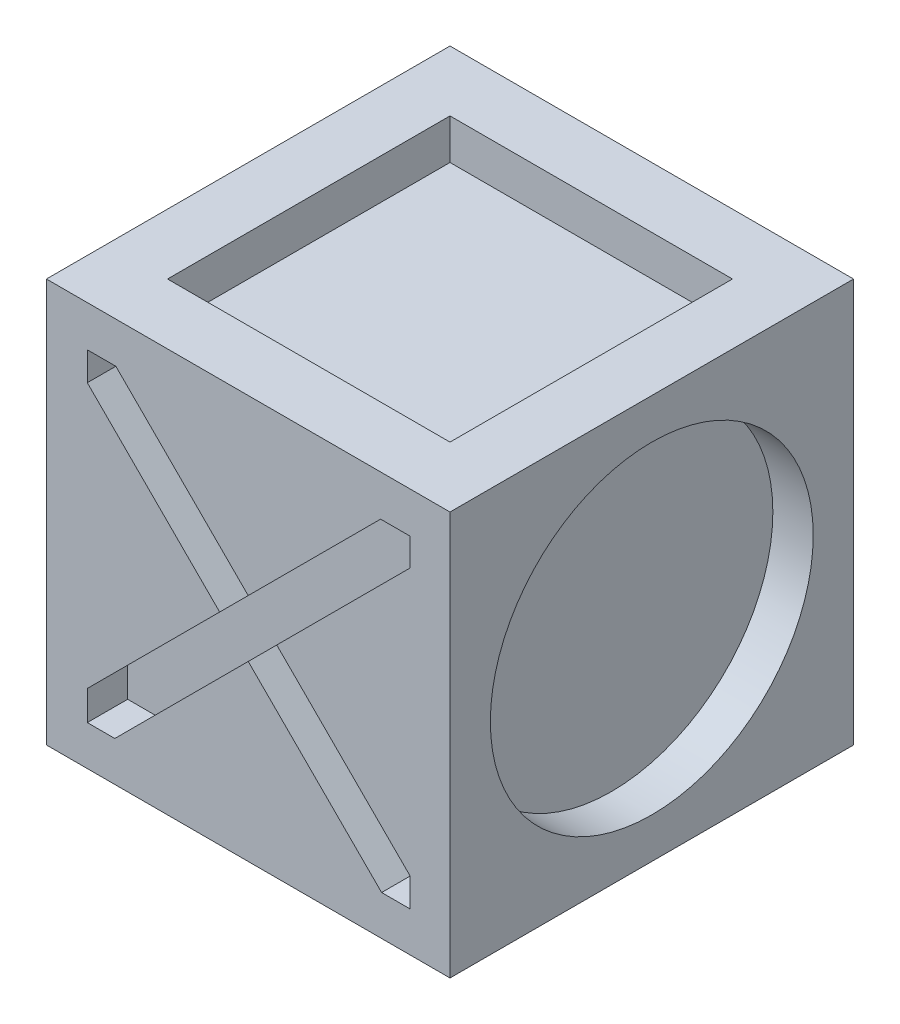
from build123d import *

# Parameters (mm, degrees)
SKETCH2_W           = 10
SKETCH2_H           = 10
BOSS_EXTRUDE1_DEPTH = 10
CUT_EXTRUDE1_DEPTH  = 1
SKETCH4_R           = 4
CUT_EXTRUDE2_DEPTH  = 1
SKETCH5_W           = 7
SKETCH5_H           = 7
CUT_EXTRUDE3_DEPTH  = 1
CUT_EXTRUDE4_DEPTH  = 1
SKETCH7_R           = 1.303792798
SKETCH7_R_2         = 2.05363311
SKETCH7_R_3         = 1.840686576
CUT_EXTRUDE5_DEPTH  = 1
CUT_EXTRUDE13_DEPTH = 0.5


with BuildPart() as part:
    # Sketch2 → Boss-Extrude1 (new body)
    with BuildSketch(Plane(origin=(0, 0, 0), x_dir=(1, 0, 0), z_dir=(0, 1, 0))):
        with Locations((5, 5)):
            Rectangle(SKETCH2_W, SKETCH2_H)
    extrude(amount=BOSS_EXTRUDE1_DEPTH)

    # Sketch3 → Cut-Extrude1 (cut)
    with BuildSketch(Plane.XY):
        Polygon((8.305584857, 0.987308362), (9.012691638, 0.987308362), (9.012691638, 1.694415143), (5.707106781, 5), (9.012691638, 8.305584857), (9.012691638, 8.987308362), (8.280201581, 8.987308362), (5, 5.707106781), (1.719798419, 8.987308362), (1.012691638, 8.987308362), (1.012691638, 8.280201581), (4.292893219, 5), (1.012691638, 1.719798419), (1.012691638, 0.987308362), (1.694415143, 0.987308362), (5, 4.292893219), align=None)
    extrude(amount=-CUT_EXTRUDE1_DEPTH, mode=Mode.SUBTRACT)

    # Sketch4 → Cut-Extrude2 (cut)
    with BuildSketch(Plane(origin=(10, 0, 0), x_dir=(0, 0, -1), z_dir=(1, 0, 0))):
        with Locations((5, 5)):
            Circle(SKETCH4_R)
    extrude(amount=-CUT_EXTRUDE2_DEPTH, mode=Mode.SUBTRACT)

    # Sketch5 → Cut-Extrude3 (cut)
    with BuildSketch(Plane(origin=(0, 10, 0), x_dir=(1, 0, 0), z_dir=(0, 1, 0))):
        with Locations((5, 5)):
            Rectangle(SKETCH5_W, SKETCH5_H)
    extrude(amount=-CUT_EXTRUDE3_DEPTH, mode=Mode.SUBTRACT)

    # Sketch6 → Cut-Extrude4 (cut)
    with BuildSketch(Plane(origin=(0, 0, -10), x_dir=(-1, 0, 0), z_dir=(0, 0, -1))):
        Polygon((-7.691273898, 8.169929887), (-1.596078599, 6.292074313), (-3.945946393, 3.612705427), (-3.762984072, 5.82237163), (-6.145851296, 4.385481263), (-2.771012496, 1.810947861), (-7.54308372, 1.463168774), (-5.754546035, 2.887207167), (-8.32224735, 4.846006741), (-5.924161107, 6.292074313), align=None)
    extrude(amount=-CUT_EXTRUDE4_DEPTH, mode=Mode.SUBTRACT)

    # Sketch7 → Cut-Extrude5 (cut)
    with BuildSketch(Plane.ZY):
        with Locations((-7.072203837, 3.137345215)):
            Circle(SKETCH7_R)
        with Locations((-5.589634204, 7.102221042)):
            Circle(SKETCH7_R_2)
        with Locations((-2.980104129, 3.137345215)):
            Circle(SKETCH7_R_3)
    extrude(amount=-CUT_EXTRUDE5_DEPTH, mode=Mode.SUBTRACT)

    # Sketch9 → Cut-Extrude13 (cut)
    with BuildSketch(Plane(origin=(0, 0, 0), x_dir=(-1, 0, 0), z_dir=(0, -1, 0))):
        Polygon((-9.041451884, 5), (-7.020725942, 1.5), (-2.979274058, 1.5), (-0.958548116, 5), (-2.979274058, 8.5), (-7.020725942, 8.5), align=None)
    extrude(amount=-CUT_EXTRUDE13_DEPTH, mode=Mode.SUBTRACT)


solid = part.part
